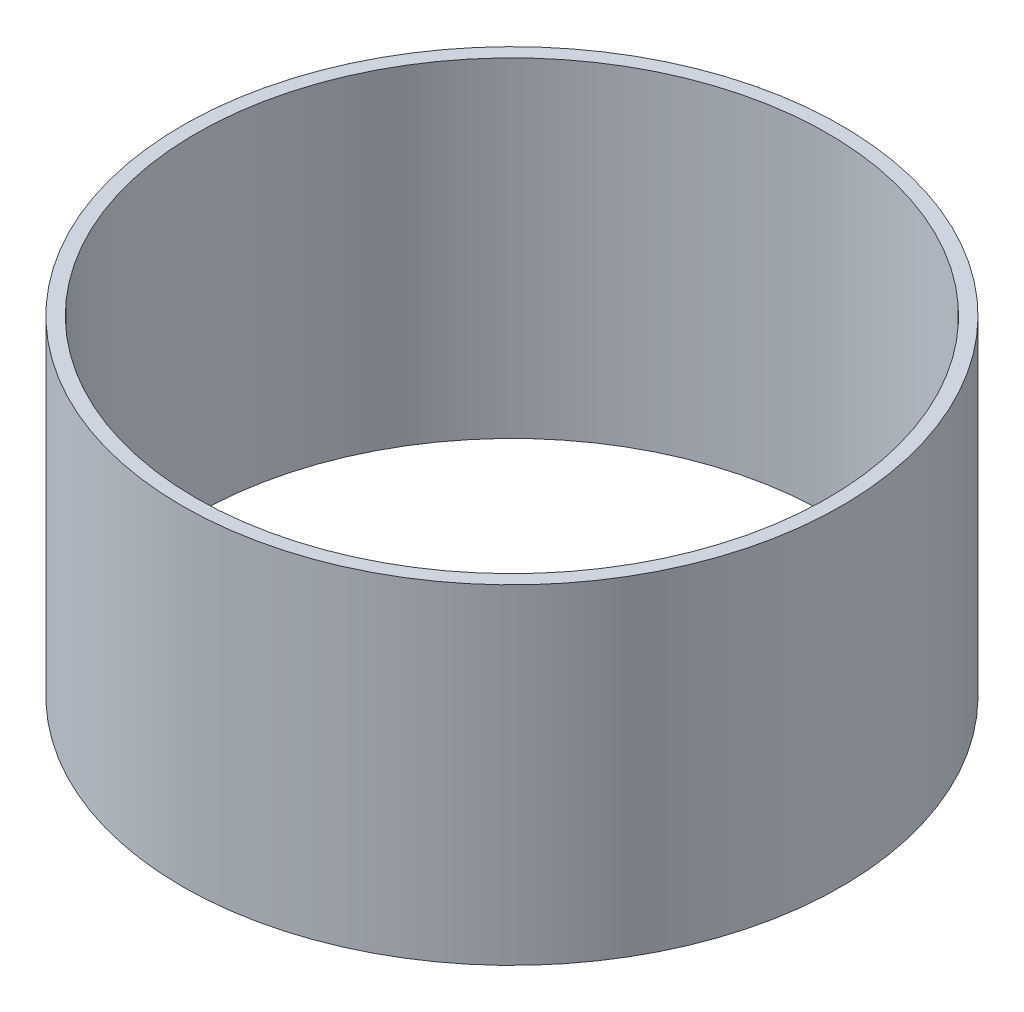
from build123d import *

# Parameters (mm, degrees)
SKETCH1_R           = 152.4
SKETCH1_R_2         = 146.05
BOSS_EXTRUDE1_DEPTH = 152.4


with BuildPart() as part:
    # Sketch1 → Boss-Extrude1 (new body)
    with BuildSketch(Plane(origin=(0, 0, 0), x_dir=(1, 0, 0), z_dir=(0, 1, 0))):
        Circle(SKETCH1_R)
        Circle(SKETCH1_R_2, mode=Mode.SUBTRACT)
    extrude(amount=BOSS_EXTRUDE1_DEPTH)


solid = part.part
